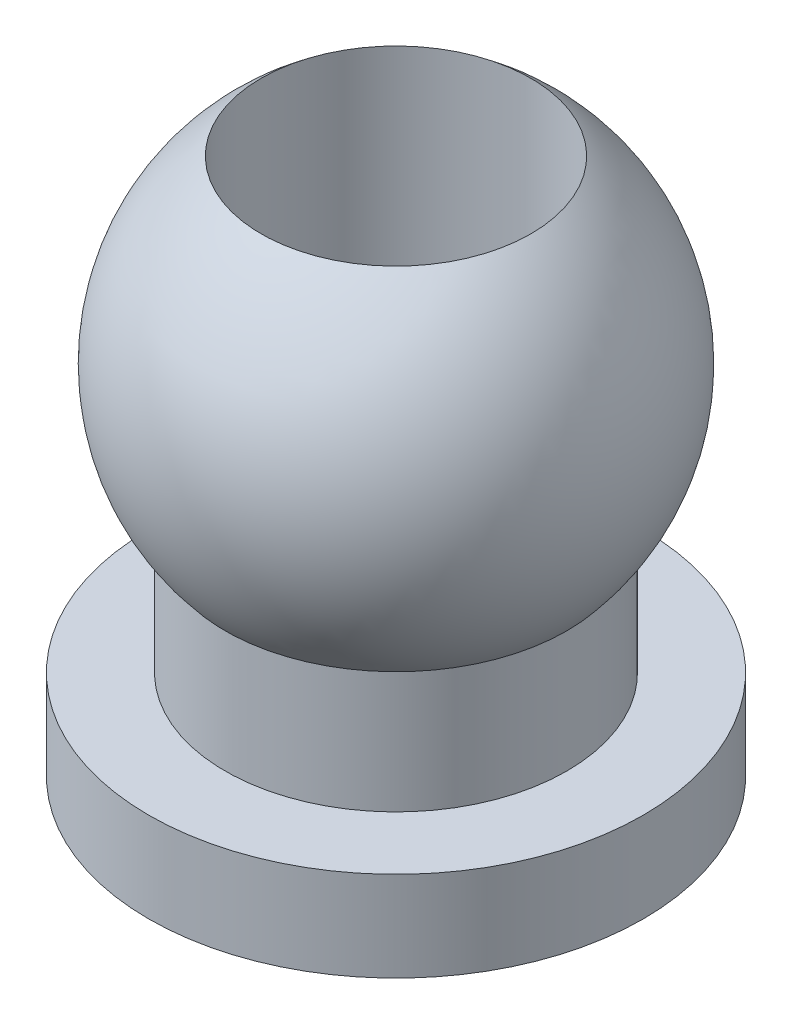
from build123d import *

# Parameters (mm, degrees)
SKETCH_3_R          = 1.5
CUT_EXTRUDE_1_DEPTH = 7


with BuildPart() as part:
    # 草圖1 → 旋轉1 (revolve)
    with BuildSketch(Plane.XY):
        with BuildLine():
            Line((0, -3.97530862), (2.75, -3.97530862))
            Line((2.75, -3.97530862), (2.75, -2.97530862))
            Line((2.75, -2.97530862), (1.9, -2.97530862))
            Line((1.9, -2.97530862), (1.9, -1.624807681))
            ThreePointArc((1.9, -1.624807681), (2.48254766, 0.29488492), (1.466500875, 2.02469138))
            Line((1.466500875, 2.02469138), (0, 2.02469138))
            Line((0, 2.02469138), (0, -3.97530862))
        make_face()
    revolve(axis=Axis((0, 2.75, 0), (0, -1, 0)))

    # 草圖3 → 除料-伸長1 (cut, through all)
    with BuildSketch(Plane.XZ.offset(3.97530862)):
        Circle(SKETCH_3_R)
    extrude(amount=-CUT_EXTRUDE_1_DEPTH, mode=Mode.SUBTRACT)


solid = part.part
